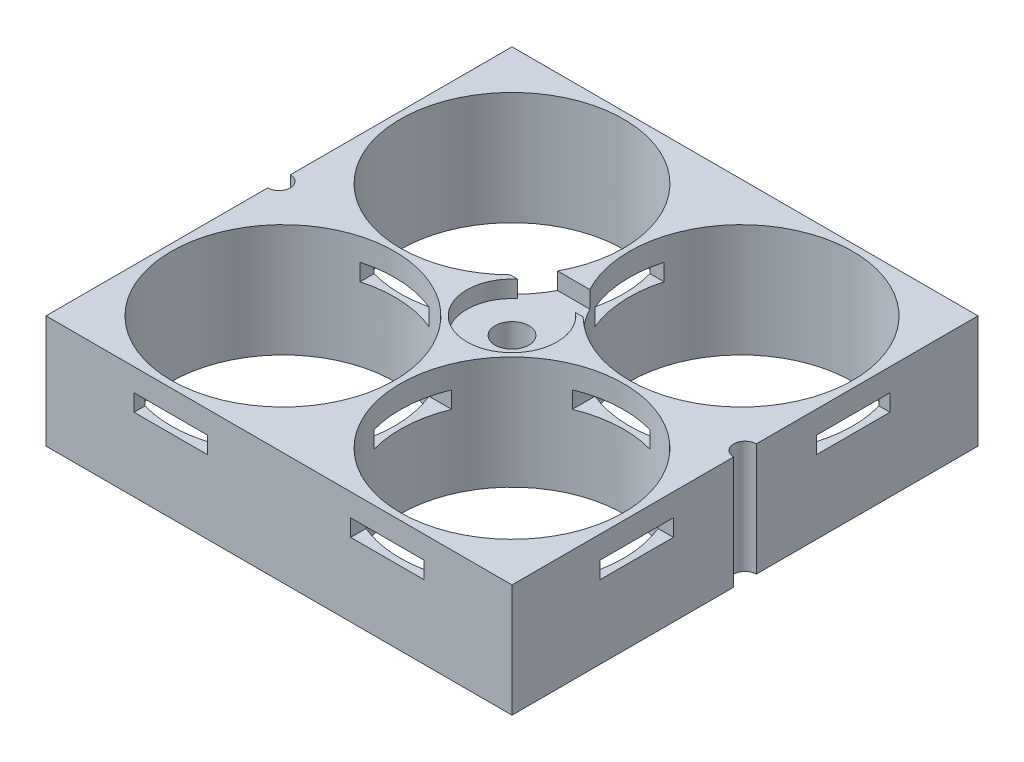
from build123d import *

# Parameters (mm, degrees)
CROQUIS1_R              = 9.9
SALIENTE_EXTRUIR1_DEPTH = 10
CROQUIS3_W              = 6.5
CROQUIS3_H              = 1.5
CORTAR_EXTRUIR1_DEPTH   = 26
MATRIZC1_COUNT          = 2
MATRIZC1_ANGLE          = 90
CORTAR_EXTRUIR3_DEPTH   = 1.5
CROQUIS6_R              = 1.5
CORTAR_EXTRUIR4_DEPTH   = 48.5


with BuildPart() as part:
    # Croquis1 → Saliente-Extruir1 (new body)
    with BuildSketch(Plane(origin=(0, 0, 0), x_dir=(1, 0, 0), z_dir=(0, 1, 0))):
        with BuildLine():
            Line((20.65, 20.65), (-20.65, 20.65))
            Line((-20.65, 20.65), (-20.65, 1))
            ThreePointArc((-20.65, 1), (-19.942893219, 0.707106781), (-19.65, 0))
            ThreePointArc((-19.65, 0), (-19.942893219, -0.707106781), (-20.65, -1))
            Line((-20.65, -1), (-20.65, -20.65))
            Line((-20.65, -20.65), (20.65, -20.65))
            Line((20.65, -20.65), (20.65, -1))
            ThreePointArc((20.65, -1), (19.65, 0), (20.65, 1))
            Line((20.65, 1), (20.65, 20.65))
        make_face()
        with Locations((-10.15, -10.15)):
            Circle(CROQUIS1_R, mode=Mode.SUBTRACT)
        with Locations((10.15, -10.15)):
            Circle(CROQUIS1_R, mode=Mode.SUBTRACT)
        with Locations((-10.15, 10.15)):
            Circle(CROQUIS1_R, mode=Mode.SUBTRACT)
        with Locations((10.15, 10.15)):
            Circle(CROQUIS1_R, mode=Mode.SUBTRACT)
    extrude(amount=SALIENTE_EXTRUIR1_DEPTH)

    # Croquis3 → Cortar-Extruir1 (cut)
    with BuildSketch(Plane.XY.offset(20.65)):
        with Locations((-9.6, 7.25)):
            Rectangle(CROQUIS3_W, CROQUIS3_H)
        with Locations((9.6, 7.25)):
            Rectangle(CROQUIS3_W, CROQUIS3_H)
    cortar_extruir1 = extrude(amount=-CORTAR_EXTRUIR1_DEPTH, mode=Mode.SUBTRACT)

    # MatrizC1: Cortar-Extruir1 ×2 about axis
    matrizc1_axis = Axis((0, 25.469690993, 0), (0, 1, 0))
    for i in range(1, MATRIZC1_COUNT):
        add(cortar_extruir1.rotate(matrizc1_axis, i * MATRIZC1_ANGLE / (MATRIZC1_COUNT - 1)), mode=Mode.SUBTRACT)

    # Croquis5 → Cortar-Extruir3 (cut)
    with BuildSketch(Plane(origin=(0, 10, 0), x_dir=(1, 0, 0), z_dir=(0, 1, 0))):
        with BuildLine():
            ThreePointArc((4, 0), (3.623813236, 1.693510446), (2.566011184, 3.068482785))
            Line((2.566011184, 3.068482785), (-2.566011184, 3.068482785))
            ThreePointArc((-2.566011184, 3.068482785), (-1.693510446, -3.623813236), (4, 0))
        make_face()
        with BuildLine():
            Line((-2.566011184, 3.068482785), (2.566011184, 3.068482785))
            ThreePointArc((2.566011184, 3.068482785), (0, 4), (-2.566011184, 3.068482785))
        make_face()
        with BuildLine():
            ThreePointArc((3.231754996, 3.068482785), (2.238589759, 4.198564207), (1.428132105, 5.466089196))
            Line((1.428132105, 5.466089196), (-1.428132105, 5.466089196))
            ThreePointArc((-1.428132105, 5.466089196), (-2.238589759, 4.198564207), (-3.231754996, 3.068482785))
            Line((-3.231754996, 3.068482785), (-2.566011184, 3.068482785))
            ThreePointArc((-2.566011184, 3.068482785), (0, 4), (2.566011184, 3.068482785))
            Line((2.566011184, 3.068482785), (3.231754996, 3.068482785))
        make_face()
    extrude(amount=-CORTAR_EXTRUIR3_DEPTH, mode=Mode.SUBTRACT)

    # Croquis6 → Cortar-Extruir4 (cut)
    with BuildSketch(Plane(origin=(0, 8.5, 0), x_dir=(1, 0, 0), z_dir=(0, 1, 0))):
        Circle(CROQUIS6_R)
    extrude(amount=-CORTAR_EXTRUIR4_DEPTH, mode=Mode.SUBTRACT)


solid = part.part
